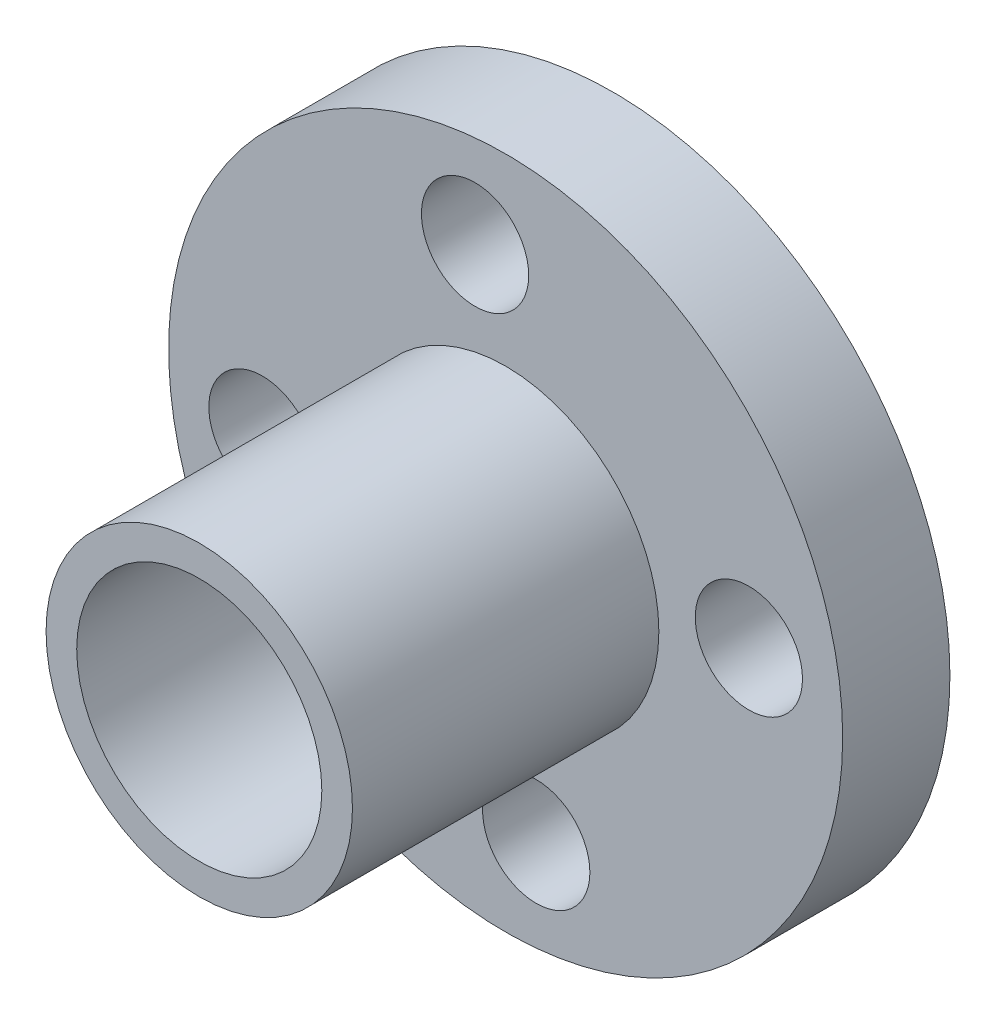
from build123d import *

# Parameters (mm, degrees)
SKETCH_1_R           = 11
EXTRUDE_1_DEPTH      = 3.5
SKETCH_2_R           = 5
EXTRUDE_2_DEPTH      = 10
EXTRUDE_2_DEPTH_BACK = 5
SKETCH_3_R           = 4
CUT_EXTRUDE_1_DEPTH  = 16
SKETCH_4_R           = 1.75
CUT_EXTRUDE_2_DEPTH  = 6


with BuildPart() as part:
    # 草图1 → 凸台-拉伸1 (new body)
    with BuildSketch(Plane.XY):
        Circle(SKETCH_1_R)
    extrude(amount=EXTRUDE_1_DEPTH)

    # 草图2 → 凸台-拉伸2 (add, two sides)
    with BuildSketch(Plane.XY.offset(3.5)) as extrude_2_sk:
        Circle(SKETCH_2_R)
    extrude(amount=EXTRUDE_2_DEPTH)
    extrude(extrude_2_sk.sketch, amount=-EXTRUDE_2_DEPTH_BACK)

    # 草图3 → 切除-拉伸1 (cut, through all)
    with BuildSketch(Plane.XY.offset(13.5)):
        Circle(SKETCH_3_R)
    extrude(amount=-CUT_EXTRUDE_1_DEPTH, mode=Mode.SUBTRACT)

    # 草图4 → 切除-拉伸2 (cut, through all)
    with BuildSketch(Plane.XY.offset(3.5)):
        with Locations((-0.998679345, 7.937420209)):
            Circle(SKETCH_4_R)
        with Locations((7.937420209, 0.998679345)):
            Circle(SKETCH_4_R)
        with Locations((0.998679345, -7.937420209)):
            Circle(SKETCH_4_R)
        with Locations((-7.937420209, -0.998679345)):
            Circle(SKETCH_4_R)
    extrude(amount=-CUT_EXTRUDE_2_DEPTH, mode=Mode.SUBTRACT)


solid = part.part
